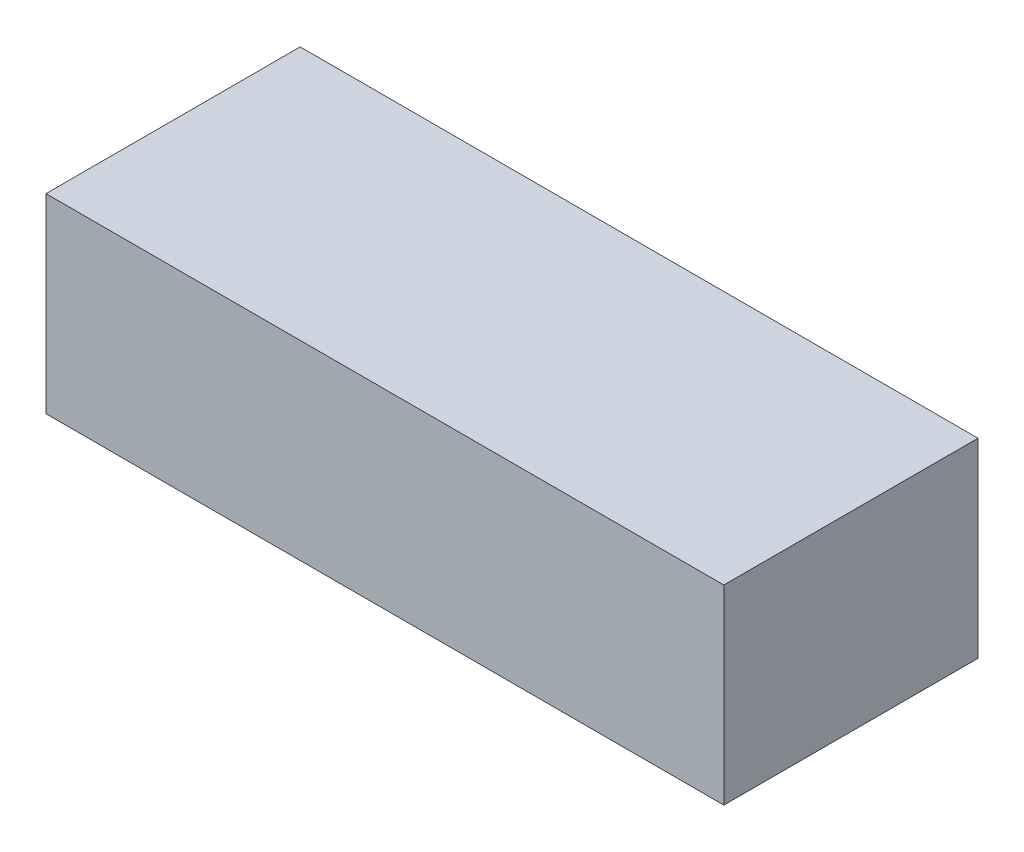
from build123d import *

# Parameters (mm, degrees)
SKETCH_1_W      = 160
SKETCH_1_H      = 60
EXTRUDE_1_DEPTH = 45


with BuildPart() as part:
    # 草图1 → 凸台-拉伸1 (new body)
    with BuildSketch(Plane(origin=(0, 0, 0), x_dir=(1, 0, 0), z_dir=(0, 1, 0))):
        with Locations((80, -30)):
            Rectangle(SKETCH_1_W, SKETCH_1_H)
    extrude(amount=EXTRUDE_1_DEPTH)


solid = part.part
